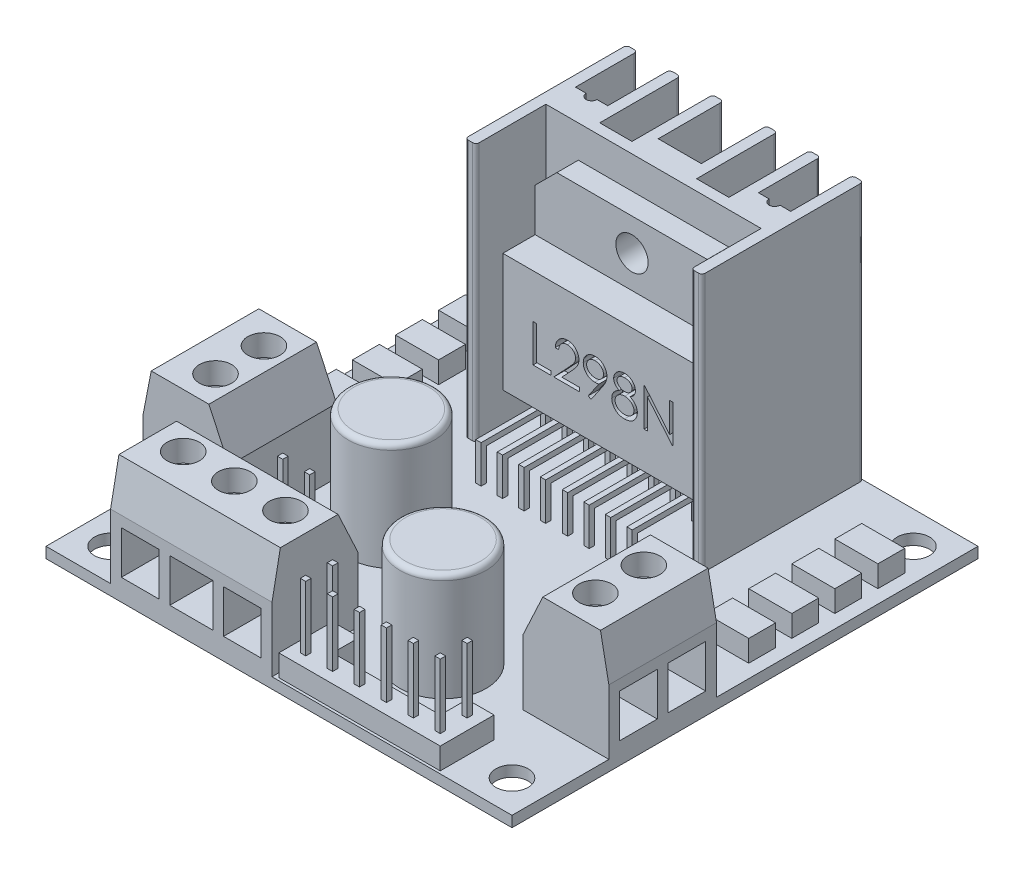
from build123d import *

# Parameters (mm, degrees)
CROQUIS1_W               = 43.3
CROQUIS1_H               = 43.3
CROQUIS1_R               = 1.5
SALIENTE_EXTRUIR1_DEPTH  = 1
CROQUIS2_W               = 1
CROQUIS2_H               = 1
CROQUIS2_H_2             = 6.5
CROQUIS2_W_2             = 3
CROQUIS2_W_3             = 2
CROQUIS2_H_3             = 1.435307759
SALIENTE_EXTRUIR2_DEPTH  = 24
CROQUIS3_W               = 8
CROQUIS3_H               = 10
SALIENTE_EXTRUIR3_DEPTH  = 10
CHAFL_N1_SIZE            = 4
CHAFL_N1_SIZE2           = 1.865230633
CHAFL_N2_SIZE            = 4
CHAFL_N2_SIZE2           = 1.865230633
CHAFL_N3_SIZE            = 4
CHAFL_N3_SIZE2           = 0.777521237
CHAFL_N4_SIZE            = 4
CHAFL_N4_SIZE2           = 0.777521237
CROQUIS4_W               = 15
CROQUIS4_H               = 8
SALIENTE_EXTRUIR4_DEPTH  = 10
CHAFL_N5_SIZE            = 4
CHAFL_N5_SIZE2           = 0.777521237
CHAFL_N6_SIZE            = 4
CHAFL_N6_SIZE2           = 1.865230633
CROQUIS5_W               = 4
CROQUIS5_H               = 2.5
SALIENTE_EXTRUIR5_DEPTH  = 2
CROQUIS6_R               = 4
SALIENTE_EXTRUIR6_DEPTH  = 10
REDONDEO1_R              = 0.5
SALIENTE_EXTRUIR7_DEPTH  = 2
CROQUIS8_W               = 2.5
CROQUIS8_H               = 2.5
SALIENTE_EXTRUIR8_DEPTH  = 2
CROQUIS9_W               = 0.25
CROQUIS9_H               = 0.25
CROQUIS9_H_2             = 0.5
CROQUIS9_W_2             = 0.5
SALIENTE_EXTRUIR9_DEPTH  = 6
CROQUIS10_W              = 0.5
CROQUIS10_H              = 0.5
SALIENTE_EXTRUIR10_DEPTH = 6
CROQUIS11_W              = 9
CROQUIS11_H              = 10
SALIENTE_EXTRUIR11_DEPTH = 5
CORTAR_EXTRUIR1_DEPTH    = 3
CROQUIS13_W              = 0.5
CROQUIS13_H              = 0.5
SALIENTE_EXTRUIR12_DEPTH = 1
CROQUIS14_W              = 0.5
CROQUIS14_H              = 0.5
SALIENTE_EXTRUIR13_DEPTH = 7
CROQUIS15_W              = 0.5
CROQUIS15_H              = 0.5
SALIENTE_EXTRUIR14_DEPTH = 4
CROQUIS16_W              = 0.5
CROQUIS16_H              = 0.5
SALIENTE_EXTRUIR15_DEPTH = 4
CORTAR_EXTRUIR2_DEPTH    = 1
CROQUIS18_R              = 1.5
CORTAR_EXTRUIR3_DEPTH    = 11.5
CROQUIS19_W              = 3.5
CROQUIS19_H              = 4
CORTAR_EXTRUIR4_DEPTH    = 4
CROQUIS20_W              = 3.5
CROQUIS20_H              = 4
CROQUIS20_W_2            = 4
CORTAR_EXTRUIR5_DEPTH    = 4
CROQUIS21_W              = 3.5
CROQUIS21_H              = 4
CORTAR_EXTRUIR6_DEPTH    = 4
CROQUIS22_R              = 1.5
CORTAR_EXTRUIR7_DEPTH    = 2
REDONDEO2_R              = 0.3
ECHELLE1_SCALE           = 1.6


with BuildPart() as part:
    # Croquis1 → Saliente-Extruir1 (new body)
    with BuildSketch(Plane(origin=(0, 0, 0), x_dir=(1, 0, 0), z_dir=(0, 1, 0))):
        with Locations((-21.65, -21.65)):
            Rectangle(CROQUIS1_W, CROQUIS1_H)
        with Locations((-40.3, -3)):
            Circle(CROQUIS1_R, mode=Mode.SUBTRACT)
        with Locations((-3, -3)):
            Circle(CROQUIS1_R, mode=Mode.SUBTRACT)
        with Locations((-40.3, -40.3)):
            Circle(CROQUIS1_R, mode=Mode.SUBTRACT)
        with Locations((-3, -40.3)):
            Circle(CROQUIS1_R, mode=Mode.SUBTRACT)
    extrude(amount=SALIENTE_EXTRUIR1_DEPTH)

    # Croquis2 → Saliente-Extruir2 (add)
    with BuildSketch(Plane(origin=(0, 1, 0), x_dir=(-1, 0, 0), z_dir=(0, 1, 0))):
        Polygon((31.65, 5.75316787), (31.65, 0), (32.65, 0), (32.65, 7.5), (31.65, 7.5), align=None)
        with Locations((32.15, 8)):
            Rectangle(CROQUIS2_W, CROQUIS2_H)
        with Locations((32.15, 11.75)):
            Rectangle(CROQUIS2_W, CROQUIS2_H_2)
        with Locations((30.15, 8)):
            Rectangle(CROQUIS2_W_2, CROQUIS2_H)
        with Locations((28.15, 8)):
            Rectangle(CROQUIS2_W, CROQUIS2_H)
        with BuildLine():
            Line((31.65, 7.5), (28.65, 7.5))
            Line((28.65, 7.5), (28.65, 5.75316787))
            Line((28.65, 5.75316787), (29.645779613, 5.75316787))
            ThreePointArc((29.645779613, 5.75316787), (30.15, 6.257388257), (30.654220387, 5.75316787))
            Line((30.654220387, 5.75316787), (31.65, 5.75316787))
            Line((31.65, 5.75316787), (31.65, 7.5))
        make_face()
        with Locations((22.65, 6.782346121)):
            Rectangle(CROQUIS2_W_3, CROQUIS2_H_3)
        with Locations((20.65, 6.782346121)):
            Rectangle(CROQUIS2_W_3, CROQUIS2_H_3)
        Polygon((23.65, 6.064692241), (23.65, 0), (24.65, 0), (24.65, 7.5), (23.65, 7.5), align=None)
        Polygon((27.65, 7.5), (27.65, 0), (28.65, 0), (28.65, 5.75316787), (28.65, 7.5), align=None)
        with Locations((26.15, 8)):
            Rectangle(CROQUIS2_W_2, CROQUIS2_H)
        with Locations((24.15, 8)):
            Rectangle(CROQUIS2_W, CROQUIS2_H)
        with Locations((22.65, 8)):
            Rectangle(CROQUIS2_W_3, CROQUIS2_H)
        with Locations((20.65, 8)):
            Rectangle(CROQUIS2_W_3, CROQUIS2_H)
        with Locations((19.15, 8)):
            Rectangle(CROQUIS2_W, CROQUIS2_H)
        Polygon((18.65, 7.5), (18.65, 0), (19.65, 0), (19.65, 6.064692241), (19.65, 7.5), align=None)
        with Locations((17.15, 8)):
            Rectangle(CROQUIS2_W_2, CROQUIS2_H)
        with Locations((15.15, 8)):
            Rectangle(CROQUIS2_W, CROQUIS2_H)
        with Locations((13.15, 8)):
            Rectangle(CROQUIS2_W_2, CROQUIS2_H)
        with Locations((11.15, 11.75)):
            Rectangle(CROQUIS2_W, CROQUIS2_H_2)
        with Locations((11.15, 8)):
            Rectangle(CROQUIS2_W, CROQUIS2_H)
        Polygon((10.65, 7.5), (10.65, 0), (11.65, 0), (11.65, 5.75316787), (11.65, 7.5), align=None)
        with BuildLine():
            Line((14.65, 7.5), (11.65, 7.5))
            Line((11.65, 7.5), (11.65, 5.75316787))
            Line((11.65, 5.75316787), (12.645779613, 5.75316787))
            ThreePointArc((12.645779613, 5.75316787), (13.15, 6.257388257), (13.654220387, 5.75316787))
            Line((13.654220387, 5.75316787), (14.65, 5.75316787))
            Line((14.65, 5.75316787), (14.65, 7.5))
        make_face()
        Polygon((14.65, 5.75316787), (14.65, 0), (15.65, 0), (15.65, 7.5), (14.65, 7.5), align=None)
    extrude(amount=SALIENTE_EXTRUIR2_DEPTH)

    # Croquis3 → Saliente-Extruir3 (add)
    with BuildSketch(Plane(origin=(0, 1, 0), x_dir=(-1, 0, 0), z_dir=(0, 1, 0))):
        with Locations((39.3, 29.3)):
            Rectangle(CROQUIS3_W, CROQUIS3_H)
        with Locations((4, 29.3)):
            Rectangle(CROQUIS3_W, CROQUIS3_H)
    extrude(amount=SALIENTE_EXTRUIR3_DEPTH)

    # Chaflán1
    chafl_n1_edges = [part.edges().sort_by_distance(p)[0] for p in [
        (-35.3, 11, 29.3),
    ]]
    chafl_n1_side = [part.faces().sort_by_distance(p)[0] for p in [
        (-35.3, 6, 29.3),
    ]]
    chamfer(chafl_n1_edges, length=CHAFL_N1_SIZE, length2=CHAFL_N1_SIZE2, reference=chafl_n1_side[0])

    # Chaflán2
    chafl_n2_edges = [part.edges().sort_by_distance(p)[0] for p in [
        (-8, 11, 29.3),
    ]]
    chafl_n2_side = [part.faces().sort_by_distance(p)[0] for p in [
        (-8, 6, 29.3),
    ]]
    chamfer(chafl_n2_edges, length=CHAFL_N2_SIZE, length2=CHAFL_N2_SIZE2, reference=chafl_n2_side[0])

    # Chaflán3
    chafl_n3_edges = [part.edges().sort_by_distance(p)[0] for p in [
        (0, 11, 29.3),
    ]]
    chafl_n3_side = [part.faces().sort_by_distance(p)[0] for p in [
        (0, 4.338101884, 26.988450803),
    ]]
    chamfer(chafl_n3_edges, length=CHAFL_N3_SIZE, length2=CHAFL_N3_SIZE2, reference=chafl_n3_side[0])

    # Chaflán4
    chafl_n4_edges = [part.edges().sort_by_distance(p)[0] for p in [
        (-43.3, 11, 29.3),
    ]]
    chafl_n4_side = [part.faces().sort_by_distance(p)[0] for p in [
        (-43.3, 4.338101884, 26.988450803),
    ]]
    chamfer(chafl_n4_edges, length=CHAFL_N4_SIZE, length2=CHAFL_N4_SIZE2, reference=chafl_n4_side[0])

    # Croquis4 → Saliente-Extruir4 (add)
    with BuildSketch(Plane(origin=(0, 1, 0), x_dir=(-1, 0, 0), z_dir=(0, 1, 0))):
        with Locations((29.8, 39.3)):
            Rectangle(CROQUIS4_W, CROQUIS4_H)
    extrude(amount=SALIENTE_EXTRUIR4_DEPTH)

    # Chaflán5
    chafl_n5_edges = [part.edges().sort_by_distance(p)[0] for p in [
        (-29.8, 11, 43.3),
    ]]
    chafl_n5_side = [part.faces().sort_by_distance(p)[0] for p in [
        (-27.97436627, 4.767977237, 43.3),
    ]]
    chamfer(chafl_n5_edges, length=CHAFL_N5_SIZE, length2=CHAFL_N5_SIZE2, reference=chafl_n5_side[0])

    # Chaflán6
    chafl_n6_edges = [part.edges().sort_by_distance(p)[0] for p in [
        (-29.8, 11, 35.3),
    ]]
    chafl_n6_side = [part.faces().sort_by_distance(p)[0] for p in [
        (-29.8, 6, 35.3),
    ]]
    chamfer(chafl_n6_edges, length=CHAFL_N6_SIZE, length2=CHAFL_N6_SIZE2, reference=chafl_n6_side[0])

    # Croquis5 → Saliente-Extruir5 (add)
    with BuildSketch(Plane(origin=(0, 1, 0), x_dir=(-1, 0, 0), z_dir=(0, 1, 0))):
        with Locations((40.060783052, 10.814133786)):
            Rectangle(CROQUIS5_W, CROQUIS5_H)
        with Locations((40.060783052, 6.814133786)):
            Rectangle(CROQUIS5_W, CROQUIS5_H)
        with Locations((40.060783052, 14.814133786)):
            Rectangle(CROQUIS5_W, CROQUIS5_H)
        with Locations((40.060783052, 18.814133786)):
            Rectangle(CROQUIS5_W, CROQUIS5_H)
        with Locations((3.239216948, 6.814133786)):
            Rectangle(CROQUIS5_W, CROQUIS5_H)
        with Locations((3.239216948, 10.814133786)):
            Rectangle(CROQUIS5_W, CROQUIS5_H)
        with Locations((3.239216948, 14.814133786)):
            Rectangle(CROQUIS5_W, CROQUIS5_H)
        with Locations((3.239216948, 18.814133786)):
            Rectangle(CROQUIS5_W, CROQUIS5_H)
    extrude(amount=SALIENTE_EXTRUIR5_DEPTH)

    # Croquis6 → Saliente-Extruir6 (add)
    with BuildSketch(Plane(origin=(0, 1, 0), x_dir=(-1, 0, 0), z_dir=(0, 1, 0))):
        with Locations((28.3, 26.210008209)):
            Circle(CROQUIS6_R)
        with Locations((15.406645961, 34.3)):
            Circle(CROQUIS6_R)
    extrude(amount=SALIENTE_EXTRUIR6_DEPTH)

    # Redondeo1
    redondeo1_edges = [part.edges().sort_by_distance(p)[0] for p in [
        (-24.3, 11, 26.210008209),
        (-11.406645961, 11, 34.3),
    ]]
    fillet(redondeo1_edges, radius=REDONDEO1_R)

    # Croquis7 → Saliente-Extruir7 (add)
    with BuildSketch(Plane(origin=(0, 1, 0), x_dir=(-1, 0, 0), z_dir=(0, 1, 0))):
        Polygon((19.407725127, 40.559550143), (19.407725127, 38.059550143), (21.907725127, 38.059550143), (21.907725127, 40.559550143), (21.907725127, 43.059550143), (6.907725127, 43.059550143), (6.907725127, 38.059550143), (9.407725127, 38.059550143), (9.407725127, 40.559550143), align=None)
    extrude(amount=SALIENTE_EXTRUIR7_DEPTH)

    # Croquis8 → Saliente-Extruir8 (add)
    with BuildSketch(Plane(origin=(0, 1, 0), x_dir=(-1, 0, 0), z_dir=(0, 1, 0))):
        with Locations((29.05, 33.05)):
            Rectangle(CROQUIS8_W, CROQUIS8_H)
        with Locations((31.55, 33.05)):
            Rectangle(CROQUIS8_W, CROQUIS8_H)
    extrude(amount=SALIENTE_EXTRUIR8_DEPTH)

    # Croquis9 → Saliente-Extruir9 (add)
    with BuildSketch(Plane(origin=(0, 3, 0), x_dir=(-1, 0, 0), z_dir=(0, 1, 0))):
        with Locations((20.532725127, 41.934550143)):
            Rectangle(CROQUIS9_W, CROQUIS9_H)
        with Locations((20.532725127, 41.684550143)):
            Rectangle(CROQUIS9_W, CROQUIS9_H)
        with Locations((20.782725127, 41.934550143)):
            Rectangle(CROQUIS9_W, CROQUIS9_H)
        with Locations((20.782725127, 41.684550143)):
            Rectangle(CROQUIS9_W, CROQUIS9_H)
        with Locations((20.532725127, 39.309550143)):
            Rectangle(CROQUIS9_W, CROQUIS9_H_2)
        with Locations((20.782725127, 39.309550143)):
            Rectangle(CROQUIS9_W, CROQUIS9_H_2)
        with Locations((18.157725127, 41.684550143)):
            Rectangle(CROQUIS9_W_2, CROQUIS9_H)
        with Locations((18.157725127, 41.934550143)):
            Rectangle(CROQUIS9_W_2, CROQUIS9_H)
        with Locations((15.657725127, 41.684550143)):
            Rectangle(CROQUIS9_W_2, CROQUIS9_H)
        with Locations((15.657725127, 41.934550143)):
            Rectangle(CROQUIS9_W_2, CROQUIS9_H)
        with Locations((13.157725127, 41.934550143)):
            Rectangle(CROQUIS9_W_2, CROQUIS9_H)
        with Locations((13.157725127, 41.684550143)):
            Rectangle(CROQUIS9_W_2, CROQUIS9_H)
        with Locations((10.657725127, 41.934550143)):
            Rectangle(CROQUIS9_W_2, CROQUIS9_H)
        with Locations((10.657725127, 41.684550143)):
            Rectangle(CROQUIS9_W_2, CROQUIS9_H)
        with Locations((8.032725127, 41.934550143)):
            Rectangle(CROQUIS9_W, CROQUIS9_H)
        with Locations((8.032725127, 41.684550143)):
            Rectangle(CROQUIS9_W, CROQUIS9_H)
        with Locations((8.282725127, 41.684550143)):
            Rectangle(CROQUIS9_W, CROQUIS9_H)
        with Locations((8.282725127, 41.934550143)):
            Rectangle(CROQUIS9_W, CROQUIS9_H)
        with Locations((8.032725127, 39.309550143)):
            Rectangle(CROQUIS9_W, CROQUIS9_H_2)
        with Locations((8.282725127, 39.309550143)):
            Rectangle(CROQUIS9_W, CROQUIS9_H_2)
    extrude(amount=SALIENTE_EXTRUIR9_DEPTH)

    # Croquis10 → Saliente-Extruir10 (add)
    with BuildSketch(Plane(origin=(0, 3, 0), x_dir=(1, 0, 0), z_dir=(0, 1, 0))):
        with Locations((-29.05, -33.05)):
            Rectangle(CROQUIS10_W, CROQUIS10_H)
        with Locations((-31.55, -33.05)):
            Rectangle(CROQUIS10_W, CROQUIS10_H)
    extrude(amount=SALIENTE_EXTRUIR10_DEPTH)

    # Croquis11 → Saliente-Extruir11 (add)
    with BuildSketch(Plane.XY.offset(8.5)):
        Polygon((-21.65, 15), (-21.65, 22), (-28.637466442, 22), (-30.65, 19.987466442), (-30.65, 15), align=None)
        Polygon((-14.662533558, 22), (-21.65, 22), (-21.65, 15), (-12.65, 15), (-12.65, 19.987466442), align=None)
        with Locations((-26.15, 10)):
            Rectangle(CROQUIS11_W, CROQUIS11_H)
        with Locations((-17.15, 10)):
            Rectangle(CROQUIS11_W, CROQUIS11_H)
    extrude(amount=SALIENTE_EXTRUIR11_DEPTH)

    # Croquis12 → Cortar-Extruir1 (cut)
    with BuildSketch(Plane.XY.offset(13.5)):
        Polygon((-14.662533558, 22), (-28.637466442, 22), (-30.65, 19.987466442), (-30.65, 16), (-12.65, 16), (-12.65, 19.987466442), align=None)
    extrude(amount=-CORTAR_EXTRUIR1_DEPTH, mode=Mode.SUBTRACT)

    # Croquis13 → Saliente-Extruir12 (add)
    with BuildSketch(Plane.XZ.offset(-5)):
        with Locations((-28.173070454, 11)):
            Rectangle(CROQUIS13_W, CROQUIS13_H)
        with Locations((-29.173070454, 11)):
            Rectangle(CROQUIS13_W, CROQUIS13_H)
        with Locations((-27.173070454, 11)):
            Rectangle(CROQUIS13_W, CROQUIS13_H)
        with Locations((-26.173070454, 11)):
            Rectangle(CROQUIS13_W, CROQUIS13_H)
        with Locations((-25.173070454, 11)):
            Rectangle(CROQUIS13_W, CROQUIS13_H)
        with Locations((-24.173070454, 11)):
            Rectangle(CROQUIS13_W, CROQUIS13_H)
        with Locations((-23.173070454, 11)):
            Rectangle(CROQUIS13_W, CROQUIS13_H)
        with Locations((-22.173070454, 11)):
            Rectangle(CROQUIS13_W, CROQUIS13_H)
        with Locations((-21.126929546, 11)):
            Rectangle(CROQUIS13_W, CROQUIS13_H)
        with Locations((-20.126929546, 11)):
            Rectangle(CROQUIS13_W, CROQUIS13_H)
        with Locations((-19.126929546, 11)):
            Rectangle(CROQUIS13_W, CROQUIS13_H)
        with Locations((-18.126929546, 11)):
            Rectangle(CROQUIS13_W, CROQUIS13_H)
        with Locations((-17.126929546, 11)):
            Rectangle(CROQUIS13_W, CROQUIS13_H)
        with Locations((-16.126929546, 11)):
            Rectangle(CROQUIS13_W, CROQUIS13_H)
        with Locations((-15.126929546, 11)):
            Rectangle(CROQUIS13_W, CROQUIS13_H)
        with Locations((-14.126929546, 11)):
            Rectangle(CROQUIS13_W, CROQUIS13_H)
    extrude(amount=SALIENTE_EXTRUIR12_DEPTH)

    # Croquis14 → Saliente-Extruir13 (add)
    with BuildSketch(Plane.XY.offset(11.25)):
        with Locations((-14.126929546, 4.25)):
            Rectangle(CROQUIS14_W, CROQUIS14_H)
        with Locations((-16.126929546, 4.25)):
            Rectangle(CROQUIS14_W, CROQUIS14_H)
        with Locations((-18.126929546, 4.25)):
            Rectangle(CROQUIS14_W, CROQUIS14_H)
        with Locations((-20.126929546, 4.25)):
            Rectangle(CROQUIS14_W, CROQUIS14_H)
        with Locations((-22.173070454, 4.25)):
            Rectangle(CROQUIS14_W, CROQUIS14_H)
        with Locations((-24.173070454, 4.25)):
            Rectangle(CROQUIS14_W, CROQUIS14_H)
        with Locations((-26.173070454, 4.25)):
            Rectangle(CROQUIS14_W, CROQUIS14_H)
        with Locations((-28.173070454, 4.25)):
            Rectangle(CROQUIS14_W, CROQUIS14_H)
    extrude(amount=SALIENTE_EXTRUIR13_DEPTH)

    # Croquis15 → Saliente-Extruir14 (add)
    with BuildSketch(Plane.XZ):
        with Locations((-28.173070454, 18)):
            Rectangle(CROQUIS15_W, CROQUIS15_H)
        with Locations((-26.173070454, 18)):
            Rectangle(CROQUIS15_W, CROQUIS15_H)
        with Locations((-24.173070454, 18)):
            Rectangle(CROQUIS15_W, CROQUIS15_H)
        with Locations((-22.173070454, 18)):
            Rectangle(CROQUIS15_W, CROQUIS15_H)
        with Locations((-20.126929546, 18)):
            Rectangle(CROQUIS15_W, CROQUIS15_H)
        with Locations((-18.126929546, 18)):
            Rectangle(CROQUIS15_W, CROQUIS15_H)
        with Locations((-16.126929546, 18)):
            Rectangle(CROQUIS15_W, CROQUIS15_H)
        with Locations((-14.126929546, 18)):
            Rectangle(CROQUIS15_W, CROQUIS15_H)
    extrude(amount=-SALIENTE_EXTRUIR14_DEPTH)

    # Croquis16 → Saliente-Extruir15 (add)
    with BuildSketch(Plane.XZ):
        with Locations((-29.173070454, 11)):
            Rectangle(CROQUIS16_W, CROQUIS16_H)
        with Locations((-27.173070454, 11)):
            Rectangle(CROQUIS16_W, CROQUIS16_H)
        with Locations((-25.173070454, 11)):
            Rectangle(CROQUIS16_W, CROQUIS16_H)
        with Locations((-23.173070454, 11)):
            Rectangle(CROQUIS16_W, CROQUIS16_H)
        with Locations((-21.126929546, 11)):
            Rectangle(CROQUIS16_W, CROQUIS16_H)
        with Locations((-19.126929546, 11)):
            Rectangle(CROQUIS16_W, CROQUIS16_H)
        with Locations((-17.126929546, 11)):
            Rectangle(CROQUIS16_W, CROQUIS16_H)
        with Locations((-15.126929546, 11)):
            Rectangle(CROQUIS16_W, CROQUIS16_H)
    extrude(amount=-SALIENTE_EXTRUIR15_DEPTH)

    # Croquis17 → Cortar-Extruir2 (cut)
    with BuildSketch(Plane.XY.offset(13.5)):
        Polygon((-27.846931762, 11.915865738), (-27.532829198, 11.915865738), (-27.532829198, 8.774840097), (-26.186675351, 8.774840097), (-26.186675351, 8.415865738), (-27.846931762, 8.415865738), align=None)
        with BuildLine():
            Line((-25.468726633, 10.838942661), (-25.782829198, 10.838942661))
            add(Edge.make_bspline(
                [(-25.782829198, 10.838942661), (-25.780782045, 10.880613549), (-25.77676149, 10.962454063), (-25.757933201, 11.08177797), (-25.730992324, 11.195832768), (-25.69290087, 11.303702682), (-25.645594592, 11.40634149), (-25.588864565, 11.503341505), (-25.521670714, 11.594332694), (-25.44546398, 11.678471537), (-25.362695341, 11.755659108), (-25.273389402, 11.822314351), (-25.179544374, 11.878632022), (-25.081444976, 11.925713264), (-24.977984412, 11.96105311), (-24.870101554, 11.98727475), (-24.757322418, 12.003051095), (-24.680482396, 12.004746881), (-24.641402915, 12.005609328)],
                knots=[0, 0, 0, 0, 0.000125083, 0.00024566, 0.000361805, 0.000476223, 0.000588214, 0.000700404, 0.000812728, 0.00092691, 0.001040529, 0.001151727, 0.001260545, 0.001368429, 0.001477521, 0.001587884, 0.001701119, 0.00181831, 0.00181831, 0.00181831, 0.00181831], degree=3))
            add(Edge.make_bspline(
                [(-24.641402915, 12.005609328), (-24.603024841, 12.004710871), (-24.527613297, 12.002945436), (-24.417551282, 11.987784407), (-24.312773988, 11.964038815), (-24.213486221, 11.930723399), (-24.120480157, 11.885938972), (-24.033057112, 11.832141433), (-23.950176301, 11.769921602), (-23.875569518, 11.696667788), (-23.807061439, 11.618465404), (-23.747959183, 11.5349775), (-23.69734602, 11.448748214), (-23.65515834, 11.359120013), (-23.624102201, 11.265248985), (-23.600523993, 11.168501782), (-23.587196579, 11.067876971), (-23.585151156, 10.999770415), (-23.584111249, 10.965144584)],
                knots=[0, 0, 0, 0, 0.000115089, 0.000226145, 0.000332614, 0.000437044, 0.000539592, 0.000641561, 0.000744629, 0.00084975, 0.000954621, 0.001056175, 0.001156101, 0.001254284, 0.001352726, 0.001452208, 0.001552655, 0.001656537, 0.001656537, 0.001656537, 0.001656537], degree=3))
            add(Edge.make_bspline(
                [(-23.584111249, 10.965144584), (-23.585804512, 10.916396749), (-23.589161323, 10.819756536), (-23.6178757, 10.677741673), (-23.662722211, 10.540148254), (-23.716719568, 10.429410952), (-23.771192012, 10.340177458), (-23.820279519, 10.266708753), (-23.87774433, 10.187603285), (-23.944422828, 10.103125947), (-24.0189357, 10.012615042), (-24.101957864, 9.916125247), (-24.194081346, 9.814653477), (-24.258739846, 9.745347876), (-24.292244262, 9.709435449)],
                knots=[0, 0, 0, 0, 0.000146118, 0.000289672, 0.0004329, 0.00057934, 0.000657978, 0.000746456, 0.000844345, 0.000951219, 0.001069268, 0.00119604, 0.001333047, 0.001480391, 0.001480391, 0.001480391, 0.001480391], degree=3))
            Line((-24.292244262, 9.709435449), (-25.167945383, 8.774840097))
            Line((-25.167945383, 8.774840097), (-23.539239454, 8.774840097))
            Line((-23.539239454, 8.774840097), (-23.539239454, 8.415865738))
            Line((-23.539239454, 8.415865738), (-25.917444582, 8.415865738))
            Line((-25.917444582, 8.415865738), (-24.560072787, 9.864383366))
            add(Edge.make_bspline(
                [(-24.560072787, 9.864383366), (-24.5270249, 9.898881673), (-24.463546673, 9.965145859), (-24.373764097, 10.061888819), (-24.293125108, 10.15163836), (-24.221107715, 10.234224909), (-24.15927421, 10.310856476), (-24.104401978, 10.37905118), (-24.060436387, 10.44180563), (-24.012720991, 10.514546244), (-23.96650701, 10.603358561), (-23.926794654, 10.711892251), (-23.902579806, 10.823619503), (-23.89967497, 10.89912154), (-23.898213813, 10.937099712)],
                knots=[0, 0, 0, 0, 0.000143319, 0.000275286, 0.00039593, 0.000505287, 0.000603949, 0.000691331, 0.000767782, 0.00083371, 0.000952247, 0.001067137, 0.001179618, 0.001293462, 0.001293462, 0.001293462, 0.001293462], degree=3))
            add(Edge.make_bspline(
                [(-23.898213813, 10.937099712), (-23.898849555, 10.960981111), (-23.900102481, 11.008046761), (-23.911160179, 11.07705252), (-23.927870685, 11.143617334), (-23.951815943, 11.207945953), (-23.983422683, 11.269391605), (-24.021896063, 11.328029085), (-24.066286126, 11.38471805), (-24.117637396, 11.437871349), (-24.174048915, 11.486552554), (-24.233643165, 11.529676639), (-24.296693269, 11.56571575), (-24.362933391, 11.595259247), (-24.432178861, 11.618434629), (-24.504563606, 11.634493208), (-24.579887622, 11.644575692), (-24.631321118, 11.645939864), (-24.657528717, 11.646634969)],
                knots=[0, 0, 0, 0, 7.16e-05, 0.00014111, 0.00020913, 0.00027724, 0.000346538, 0.000415963, 0.000487357, 0.000562233, 0.000637292, 0.000710646, 0.000782564, 0.000854749, 0.000927915, 0.001001225, 0.001076884, 0.001155488, 0.001155488, 0.001155488, 0.001155488], degree=3))
            add(Edge.make_bspline(
                [(-24.657528717, 11.646634969), (-24.68489955, 11.645919936), (-24.738651346, 11.644515731), (-24.817570379, 11.634693067), (-24.892856156, 11.617747227), (-24.964698059, 11.594570552), (-25.033217645, 11.565112004), (-25.098081689, 11.528420259), (-25.159144578, 11.484636766), (-25.216521102, 11.434996209), (-25.269385081, 11.379728608), (-25.315831957, 11.318118645), (-25.356415971, 11.25129123), (-25.391825204, 11.179426679), (-25.420580894, 11.101872899), (-25.442554045, 11.018905194), (-25.459940891, 10.930883813), (-25.465749412, 10.870098728), (-25.468726633, 10.838942661)],
                knots=[0, 0, 0, 0, 8.2106e-05, 0.000161243, 0.000238127, 0.000313291, 0.000387401, 0.000461495, 0.000536397, 0.000612445, 0.000688819, 0.000765383, 0.000843422, 0.000923066, 0.001005373, 0.001091093, 0.001180334, 0.001274175, 0.001274175, 0.001274175, 0.001274175], degree=3))
        make_face()
        with BuildLine():
            Line((-22.462316377, 8.326122148), (-22.71331798, 8.500701475))
            Line((-22.71331798, 8.500701475), (-21.740160928, 9.923277597))
            add(Edge.make_bspline(
                [(-21.740160928, 9.923277597), (-21.802251664, 9.915684534), (-21.924511784, 9.900733369), (-22.047648886, 9.897986714), (-22.108249871, 9.896634969)],
                knots=[0, 0, 0, 0, 0.000187529, 0.000369255, 0.000369255, 0.000369255, 0.000369255], degree=3))
            add(Edge.make_bspline(
                [(-22.108249871, 9.896634969), (-22.144991918, 9.897576045), (-22.217113345, 9.899423296), (-22.323144998, 9.914065104), (-22.425030558, 9.936615232), (-22.522499914, 9.970263987), (-22.615919419, 10.012082196), (-22.705085133, 10.06393921), (-22.789877023, 10.124945501), (-22.869384433, 10.194778493), (-22.941696172, 10.271456545), (-23.00611947, 10.352612188), (-23.059660602, 10.439188159), (-23.104137187, 10.529418378), (-23.137867641, 10.624599729), (-23.162430178, 10.723649129), (-23.177552532, 10.827260771), (-23.179351628, 10.897785902), (-23.180265095, 10.933594103)],
                knots=[0, 0, 0, 0, 0.000110185, 0.000216284, 0.000320547, 0.000422759, 0.000525058, 0.000627155, 0.000731643, 0.000837964, 0.0009441, 0.00104747, 0.001148247, 0.001248901, 0.001348697, 0.001450555, 0.001554666, 0.00166205, 0.00166205, 0.00166205, 0.00166205], degree=3))
            add(Edge.make_bspline(
                [(-23.180265095, 10.933594103), (-23.17853066, 10.982562756), (-23.175126317, 11.078678288), (-23.147727799, 11.219112057), (-23.10266746, 11.3518986), (-23.039839083, 11.476688794), (-22.960704362, 11.591687533), (-22.865595772, 11.695296142), (-22.755091807, 11.786040996), (-22.631709788, 11.864045074), (-22.498356768, 11.926780071), (-22.358688109, 11.973019371), (-22.213773989, 12.000218119), (-22.115606319, 12.00380398), (-22.066182563, 12.005609328)],
                knots=[0, 0, 0, 0, 0.000146818, 0.000288173, 0.000427413, 0.000566316, 0.000705952, 0.000844895, 0.000986821, 0.001133677, 0.001281714, 0.001427825, 0.001574003, 0.00172222, 0.00172222, 0.00172222, 0.00172222], degree=3))
            add(Edge.make_bspline(
                [(-22.066182563, 12.005609328), (-22.017694143, 12.003779165), (-21.921885596, 12.000162935), (-21.78099659, 11.973678966), (-21.646055573, 11.929042293), (-21.517810586, 11.867357729), (-21.399071174, 11.790036822), (-21.292295363, 11.697902298), (-21.199919824, 11.590896771), (-21.122095943, 11.471608281), (-21.059625903, 11.343441299), (-21.01455362, 11.209657377), (-20.986807981, 11.071218656), (-20.983311654, 10.977424181), (-20.981547146, 10.930088494)],
                knots=[0, 0, 0, 0, 0.000145418, 0.000287333, 0.000428343, 0.000570713, 0.000713061, 0.00085223, 0.000992387, 0.001135706, 0.001278381, 0.001418948, 0.001558239, 0.001700158, 0.001700158, 0.001700158, 0.001700158], degree=3))
            add(Edge.make_bspline(
                [(-20.981547146, 10.930088494), (-20.982725555, 10.893344727), (-20.985115663, 10.818819186), (-21.00185197, 10.705588844), (-21.030272155, 10.590137614), (-21.062523854, 10.492416018), (-21.093656022, 10.411707569), (-21.122957153, 10.347955989), (-21.155469307, 10.280854725), (-21.193388072, 10.211107387), (-21.234150369, 10.137824852), (-21.280209646, 10.061742137), (-21.330515217, 9.982757144), (-21.366344937, 9.929510056), (-21.384692178, 9.902243943)],
                knots=[0, 0, 0, 0, 0.000110219, 0.000223552, 0.000342587, 0.000466527, 0.000532018, 0.000601997, 0.000676938, 0.00075567, 0.000840114, 0.000928491, 0.001022434, 0.001121023, 0.001121023, 0.001121023, 0.001121023], degree=3))
            Line((-21.384692178, 9.902243943), (-22.462316377, 8.326122148))
        make_face()
        with BuildLine():
            add(Edge.make_bspline(
                [(-22.050056762, 10.255609328), (-22.022222748, 10.256369711), (-21.968039384, 10.25784992), (-21.888662085, 10.266859162), (-21.813737882, 10.282833148), (-21.743066633, 10.30575286), (-21.675939731, 10.333409529), (-21.613423403, 10.368621515), (-21.555465327, 10.41063815), (-21.5016774, 10.457848166), (-21.453913401, 10.510298749), (-21.41137037, 10.565195856), (-21.375209802, 10.622780466), (-21.346646525, 10.683773728), (-21.32316195, 10.746690937), (-21.306943938, 10.812545292), (-21.297959605, 10.880993693), (-21.29642803, 10.927492351), (-21.29564971, 10.951122148)],
                knots=[0, 0, 0, 0, 8.3507e-05, 0.00016256, 0.000239294, 0.000312908, 0.000385178, 0.000456751, 0.000527578, 0.000599603, 0.000671055, 0.000740051, 0.000807755, 0.000874553, 0.000941763, 0.001008931, 0.001077548, 0.001148448, 0.001148448, 0.001148448, 0.001148448], degree=3))
            add(Edge.make_bspline(
                [(-21.29564971, 10.951122148), (-21.29631938, 10.974761813), (-21.297639045, 11.021346673), (-21.308226344, 11.089896413), (-21.326851568, 11.155589674), (-21.351842052, 11.218786104), (-21.38476229, 11.278966476), (-21.424265776, 11.336886348), (-21.471198226, 11.392178475), (-21.525200792, 11.443542459), (-21.583435345, 11.490890358), (-21.645495845, 11.532676434), (-21.710870761, 11.567697631), (-21.779161251, 11.5965966), (-21.8505096, 11.619148376), (-21.924873588, 11.635365741), (-22.002628994, 11.644337495), (-22.05541028, 11.64585939), (-22.082308364, 11.646634969)],
                knots=[0, 0, 0, 0, 7.09e-05, 0.000139717, 0.000207422, 0.000275384, 0.000343146, 0.000412766, 0.000485392, 0.000560268, 0.000636041, 0.000710323, 0.000784354, 0.000858188, 0.000932471, 0.001008519, 0.001086179, 0.001166885, 0.001166885, 0.001166885, 0.001166885], degree=3))
            add(Edge.make_bspline(
                [(-22.082308364, 11.646634969), (-22.108972518, 11.645858137), (-22.161287367, 11.644334), (-22.238351526, 11.635382794), (-22.312212694, 11.61903931), (-22.383354314, 11.596607046), (-22.451642775, 11.567695475), (-22.517014608, 11.532674599), (-22.579089624, 11.490899977), (-22.637268345, 11.443505204), (-22.691366267, 11.392417558), (-22.737491796, 11.336644129), (-22.777085688, 11.278996605), (-22.809960691, 11.218778097), (-22.834963208, 11.155591811), (-22.85358521, 11.089895834), (-22.864173375, 11.021346824), (-22.865492922, 10.974761864), (-22.866162531, 10.951122148)],
                knots=[0, 0, 0, 0, 8.0005e-05, 0.000156969, 0.000232332, 0.000306614, 0.000380449, 0.000454479, 0.000528762, 0.000604535, 0.000679411, 0.000751586, 0.000821205, 0.000888968, 0.00095693, 0.001024634, 0.001093451, 0.001164351, 0.001164351, 0.001164351, 0.001164351], degree=3))
            add(Edge.make_bspline(
                [(-22.866162531, 10.951122148), (-22.865556605, 10.927473949), (-22.864361608, 10.880835373), (-22.852833818, 10.81230898), (-22.833555538, 10.746620786), (-22.807736147, 10.683132079), (-22.773734557, 10.622460221), (-22.732010709, 10.564892859), (-22.683105163, 10.509777409), (-22.627671676, 10.457970197), (-22.567003515, 10.410418022), (-22.502206769, 10.36888764), (-22.434396932, 10.333815195), (-22.363335301, 10.305673811), (-22.289548501, 10.283062148), (-22.21237337, 10.266888603), (-22.132065132, 10.257936336), (-22.07765515, 10.256392439), (-22.050056762, 10.255609328)],
                knots=[0, 0, 0, 0, 7.09e-05, 0.000139828, 0.000207725, 0.00027595, 0.000345002, 0.000415829, 0.000488844, 0.000565728, 0.000643147, 0.000719775, 0.000796287, 0.0008718, 0.000948761, 0.001027552, 0.001107998, 0.001190805, 0.001190805, 0.001190805, 0.001190805], degree=3))
        make_face(mode=Mode.SUBTRACT)
        with BuildLine():
            add(Edge.make_bspline(
                [(-18.831206601, 10.365685449), (-18.802558054, 10.350747493), (-18.74668382, 10.321613491), (-18.667106611, 10.274702663), (-18.59438161, 10.225261698), (-18.526491048, 10.175625839), (-18.464627698, 10.123894187), (-18.409483285, 10.069861031), (-18.359695665, 10.014875086), (-18.316268881, 9.958005246), (-18.278072044, 9.899402596), (-18.245059909, 9.838913323), (-18.216842706, 9.77666999), (-18.194479767, 9.71199316), (-18.176057976, 9.645832898), (-18.163382371, 9.577334916), (-18.156565453, 9.506950575), (-18.155276639, 9.459382274), (-18.154624069, 9.435296828)],
                knots=[0, 0, 0, 0, 9.692e-05, 0.000189026, 0.000276921, 0.000360637, 0.000441251, 0.000518597, 0.000592078, 0.000663595, 0.000733021, 0.000801734, 0.000870147, 0.000937778, 0.001006834, 0.001076004, 0.001146466, 0.001218736, 0.001218736, 0.001218736, 0.001218736], degree=3))
            add(Edge.make_bspline(
                [(-18.154624069, 9.435296828), (-18.15539549, 9.401599095), (-18.156922421, 9.334898638), (-18.170222405, 9.236452527), (-18.190135383, 9.140840745), (-18.219214895, 9.048084254), (-18.256928286, 8.958694881), (-18.303405122, 8.872596107), (-18.356016327, 8.788376798), (-18.398268567, 8.736557396), (-18.419648108, 8.710336892)],
                knots=[0, 0, 0, 0, 0.000101049, 0.000200014, 0.00029751, 0.000393751, 0.000491154, 0.000588073, 0.000687071, 0.000788472, 0.000788472, 0.000788472, 0.000788472], degree=3))
            add(Edge.make_bspline(
                [(-18.419648108, 8.710336892), (-18.447484582, 8.679743118), (-18.502813548, 8.618933625), (-18.597596475, 8.539982815), (-18.701618359, 8.473633421), (-18.814476692, 8.419561526), (-18.935869793, 8.377475667), (-19.065771798, 8.347233149), (-19.204435951, 8.32991072), (-19.299741422, 8.327406731), (-19.348634486, 8.326122148)],
                knots=[0, 0, 0, 0, 0.000123978, 0.000246423, 0.000368759, 0.000493253, 0.000620972, 0.000753455, 0.000892683, 0.001039354, 0.001039354, 0.001039354, 0.001039354], degree=3))
            add(Edge.make_bspline(
                [(-19.348634486, 8.326122148), (-19.395647875, 8.327274626), (-19.487131154, 8.329517231), (-19.620289031, 8.344711663), (-19.744412101, 8.371339529), (-19.860222069, 8.407784139), (-19.967020763, 8.455194367), (-20.064503864, 8.514202776), (-20.154077836, 8.582434218), (-20.23302431, 8.661848296), (-20.303112753, 8.746906168), (-20.364680807, 8.834657778), (-20.415854885, 8.925111136), (-20.45918198, 9.016917503), (-20.492350003, 9.111363657), (-20.515322213, 9.20796367), (-20.529911527, 9.306548813), (-20.531852662, 9.373080466), (-20.532829198, 9.406550834)],
                knots=[0, 0, 0, 0, 0.000141037, 0.000274444, 0.00040137, 0.000521327, 0.000638076, 0.000750983, 0.00086247, 0.000975011, 0.001086056, 0.001192834, 0.001296147, 0.001397463, 0.001497025, 0.001595826, 0.001694979, 0.00179536, 0.00179536, 0.00179536, 0.00179536], degree=3))
            add(Edge.make_bspline(
                [(-20.532829198, 9.406550834), (-20.532251316, 9.431110026), (-20.53110922, 9.479647658), (-20.523204371, 9.551356986), (-20.51049591, 9.621153121), (-20.493236453, 9.689293865), (-20.469845427, 9.755283137), (-20.441603294, 9.819433611), (-20.408671341, 9.88181771), (-20.370590176, 9.942776591), (-20.326288152, 10.001456103), (-20.276124502, 10.058852098), (-20.219096634, 10.114073965), (-20.155838975, 10.16779639), (-20.087074435, 10.220972364), (-20.011016905, 10.270728092), (-19.929682637, 10.320586057), (-19.871877231, 10.350394382), (-19.84222423, 10.365685449)],
                knots=[0, 0, 0, 0, 7.3671e-05, 0.0001456, 0.000216149, 0.000286381, 0.000356229, 0.000425923, 0.00049649, 0.000567687, 0.000641305, 0.000716824, 0.000796154, 0.000879197, 0.00096572, 0.001056725, 0.001151716, 0.001251771, 0.001251771, 0.001251771, 0.001251771], degree=3))
            add(Edge.make_bspline(
                [(-19.84222423, 10.365685449), (-19.882815604, 10.387820218), (-19.961411867, 10.430679326), (-20.065481308, 10.509426132), (-20.154871932, 10.594713947), (-20.227126649, 10.688343741), (-20.283998877, 10.787390616), (-20.323017482, 10.891234868), (-20.349413966, 10.997950982), (-20.352028793, 11.070857178), (-20.353342018, 11.107472308)],
                knots=[0, 0, 0, 0, 0.000138535, 0.000268243, 0.000390218, 0.00050816, 0.000621822, 0.000731457, 0.000840134, 0.00094978, 0.00094978, 0.00094978, 0.00094978], degree=3))
            add(Edge.make_bspline(
                [(-20.353342018, 11.107472308), (-20.351706594, 11.144769867), (-20.348419106, 11.219744464), (-20.321835786, 11.331350587), (-20.278515719, 11.440967152), (-20.219594722, 11.548062865), (-20.146207506, 11.64901308), (-20.05816096, 11.739554026), (-19.957557663, 11.818865508), (-19.844899796, 11.885441681), (-19.723663561, 11.93962534), (-19.595747837, 11.977003763), (-19.463381344, 12.001439879), (-19.373283624, 12.004206534), (-19.327600832, 12.005609328)],
                knots=[0, 0, 0, 0, 0.000111795, 0.000224728, 0.000342168, 0.000464543, 0.000590474, 0.000715423, 0.000842224, 0.000973648, 0.001107055, 0.001239485, 0.001372621, 0.001509557, 0.001509557, 0.001509557, 0.001509557], degree=3))
            add(Edge.make_bspline(
                [(-19.327600832, 12.005609328), (-19.283097017, 12.004162985), (-19.195340564, 12.001310961), (-19.066345936, 11.977524083), (-18.942921059, 11.937794563), (-18.82549156, 11.88389734), (-18.716159693, 11.817510399), (-18.619557383, 11.737109525), (-18.534224801, 11.646967974), (-18.463640407, 11.546048371), (-18.405477518, 11.439364177), (-18.364976617, 11.327741656), (-18.339024643, 11.213592597), (-18.335751278, 11.136354593), (-18.334111249, 11.097656603)],
                knots=[0, 0, 0, 0, 0.000133436, 0.000263121, 0.000391946, 0.000521517, 0.000649943, 0.000774455, 0.000897469, 0.001021193, 0.0011429, 0.001260905, 0.001376422, 0.001492413, 0.001492413, 0.001492413, 0.001492413], degree=3))
            add(Edge.make_bspline(
                [(-18.334111249, 11.097656603), (-18.335545809, 11.059679939), (-18.338363205, 10.98509593), (-18.362063145, 10.87636941), (-18.401976458, 10.774547371), (-18.456470621, 10.678474419), (-18.527496109, 10.589892921), (-18.614104842, 10.507676451), (-18.71560632, 10.431149623), (-18.791867206, 10.387963258), (-18.831206601, 10.365685449)],
                knots=[0, 0, 0, 0, 0.000113843, 0.000223582, 0.000331909, 0.000440874, 0.000553657, 0.00067118, 0.000798364, 0.000933876, 0.000933876, 0.000933876, 0.000933876], degree=3))
        make_face()
        with BuildLine():
            add(Edge.make_bspline(
                [(-19.345128877, 11.646634969), (-19.369679683, 11.645983528), (-19.417711794, 11.644709026), (-19.488140465, 11.638050389), (-19.555112832, 11.625097172), (-19.619328633, 11.60785846), (-19.679907445, 11.584570472), (-19.737672, 11.557175463), (-19.79163919, 11.523869397), (-19.842460493, 11.486508199), (-19.888211267, 11.445415293), (-19.928815819, 11.402601575), (-19.962543933, 11.357226182), (-19.991185043, 11.310417823), (-20.01196656, 11.260787247), (-20.027530864, 11.20985607), (-20.038052255, 11.156980686), (-20.038840645, 11.120844176), (-20.039239454, 11.102564456)],
                knots=[0, 0, 0, 0, 7.3671e-05, 0.000144133, 0.000211925, 0.000278091, 0.000343329, 0.00040636, 0.000469609, 0.000533272, 0.00059534, 0.000653874, 0.000709964, 0.000764674, 0.00081807, 0.000870854, 0.000924347, 0.000979106, 0.000979106, 0.000979106, 0.000979106], degree=3))
            add(Edge.make_bspline(
                [(-20.039239454, 11.102564456), (-20.038552087, 11.084283946), (-20.037193751, 11.048159033), (-20.026688623, 10.994813167), (-20.011031768, 10.942391531), (-19.986381107, 10.89214062), (-19.956814749, 10.84231726), (-19.920323273, 10.794166674), (-19.876834245, 10.74752129), (-19.827806804, 10.702777848), (-19.774395267, 10.660879085), (-19.717811223, 10.624505904), (-19.658764832, 10.594071793), (-19.597862763, 10.568742388), (-19.534484315, 10.549052451), (-19.469017842, 10.535083805), (-19.40145234, 10.526401808), (-19.355671759, 10.525364787), (-19.332508685, 10.524840097)],
                knots=[0, 0, 0, 0, 5.48e-05, 0.000108292, 0.000162623, 0.00021845, 0.000275685, 0.000336262, 0.000399273, 0.000466763, 0.000535204, 0.00060269, 0.000668229, 0.000734243, 0.000800327, 0.000867022, 0.000934854, 0.001004321, 0.001004321, 0.001004321, 0.001004321], degree=3))
            add(Edge.make_bspline(
                [(-19.332508685, 10.524840097), (-19.302758581, 10.525712964), (-19.243552213, 10.527450077), (-19.156272882, 10.543601251), (-19.071410237, 10.569007168), (-18.989871333, 10.603767135), (-18.913766748, 10.647394995), (-18.845926679, 10.699628013), (-18.786929787, 10.75926011), (-18.737389176, 10.825362946), (-18.69897933, 10.895714534), (-18.669077522, 10.966314827), (-18.651616307, 11.037917058), (-18.64933874, 11.085884022), (-18.648213813, 11.109575674)],
                knots=[0, 0, 0, 0, 8.9178e-05, 0.000177474, 0.000265314, 0.000354521, 0.00044279, 0.000527774, 0.000610569, 0.000693722, 0.000774691, 0.000850468, 0.000923253, 0.000994288, 0.000994288, 0.000994288, 0.000994288], degree=3))
            add(Edge.make_bspline(
                [(-18.648213813, 11.109575674), (-18.64874571, 11.12620371), (-18.649801451, 11.159207978), (-18.658501507, 11.207946343), (-18.67287734, 11.255575927), (-18.69234042, 11.302490197), (-18.717950215, 11.348030929), (-18.748314402, 11.392914017), (-18.785198904, 11.436129781), (-18.826595337, 11.47868533), (-18.873540746, 11.518069353), (-18.925944658, 11.552704064), (-18.983538408, 11.58211642), (-19.046323358, 11.606005175), (-19.114068282, 11.623947525), (-19.186461157, 11.637383872), (-19.264105604, 11.644956984), (-19.317535355, 11.646063509), (-19.345128877, 11.646634969)],
                knots=[0, 0, 0, 0, 4.9859e-05, 9.8962e-05, 0.000147986, 0.000198898, 0.000250994, 0.000304472, 0.000361207, 0.000421197, 0.00048242, 0.000544646, 0.00060924, 0.000676039, 0.000745771, 0.000819205, 0.000896713, 0.000979493, 0.000979493, 0.000979493, 0.000979493], degree=3))
        make_face(mode=Mode.SUBTRACT)
        with BuildLine():
            add(Edge.make_bspline(
                [(-19.324796345, 10.165865738), (-19.355922131, 10.165312097), (-19.416983327, 10.164225987), (-19.506440255, 10.152136487), (-19.592293421, 10.135307094), (-19.674253357, 10.109776255), (-19.752285454, 10.076579765), (-19.826812136, 10.036645225), (-19.897263266, 9.989439782), (-19.962665992, 9.935563166), (-20.022389322, 9.877503712), (-20.074787622, 9.816041577), (-20.119285142, 9.752319044), (-20.155118393, 9.685526815), (-20.184530125, 9.617079204), (-20.203844002, 9.545271609), (-20.216225714, 9.471484496), (-20.217888346, 9.421324397), (-20.218726633, 9.396034007)],
                knots=[0, 0, 0, 0, 9.3315e-05, 0.000183061, 0.000270376, 0.000355532, 0.000440046, 0.000524429, 0.000608823, 0.000694017, 0.000778303, 0.000858382, 0.000935982, 0.001010962, 0.001085443, 0.001158927, 0.001233504, 0.001309342, 0.001309342, 0.001309342, 0.001309342], degree=3))
            add(Edge.make_bspline(
                [(-20.218726633, 9.396034007), (-20.217363375, 9.364603101), (-20.214658701, 9.302244918), (-20.193202062, 9.210081846), (-20.158766527, 9.120860792), (-20.110741311, 9.035308839), (-20.051273738, 8.955358732), (-19.97814727, 8.885669957), (-19.895906433, 8.823748478), (-19.801768579, 8.773667945), (-19.698940112, 8.73367309), (-19.587448384, 8.706117127), (-19.468893465, 8.687875677), (-19.387033873, 8.686037496), (-19.345128877, 8.685096507)],
                knots=[0, 0, 0, 0, 9.4212e-05, 0.000186914, 0.000282354, 0.00038028, 0.000480401, 0.000580061, 0.000682286, 0.000788322, 0.000898864, 0.001012456, 0.001132235, 0.001257861, 0.001257861, 0.001257861, 0.001257861], degree=3))
            add(Edge.make_bspline(
                [(-19.345128877, 8.685096507), (-19.312378509, 8.685725316), (-19.24857029, 8.686950436), (-19.155484341, 8.69776473), (-19.067639793, 8.714914355), (-18.985206994, 8.739857901), (-18.907263154, 8.770307877), (-18.8351298, 8.809479959), (-18.766951273, 8.854032282), (-18.706087151, 8.906890438), (-18.650653942, 8.963369933), (-18.602320649, 9.023159976), (-18.560363098, 9.084635609), (-18.527432142, 9.149186093), (-18.501105889, 9.215573008), (-18.482182334, 9.284408519), (-18.470506119, 9.355903752), (-18.469325223, 9.404402823), (-18.468726633, 9.428986731)],
                knots=[0, 0, 0, 0, 9.822e-05, 0.000191363, 0.000280739, 0.000366362, 0.000449427, 0.000531293, 0.000612187, 0.000693253, 0.000772583, 0.000849342, 0.000923624, 0.000995434, 0.001066261, 0.001137531, 0.001209227, 0.001282928, 0.001282928, 0.001282928, 0.001282928], degree=3))
            add(Edge.make_bspline(
                [(-18.468726633, 9.428986731), (-18.469632482, 9.452864072), (-18.471418657, 9.499946017), (-18.482755348, 9.569712543), (-18.502671226, 9.637115358), (-18.529998622, 9.702965364), (-18.566379585, 9.765928314), (-18.609224455, 9.827644486), (-18.660918574, 9.88640093), (-18.71933117, 9.942654026), (-18.782990131, 9.994669763), (-18.850657275, 10.040684202), (-18.921811737, 10.079436318), (-18.996302948, 10.110952813), (-19.073965504, 10.135740283), (-19.154742283, 10.153056278), (-19.238727858, 10.163955881), (-19.295782728, 10.165221927), (-19.324796345, 10.165865738)],
                knots=[0, 0, 0, 0, 7.1638e-05, 0.000141258, 0.00021137, 0.000282076, 0.000354604, 0.000429101, 0.000507127, 0.000588942, 0.000672164, 0.000753448, 0.00083408, 0.000914819, 0.000995752, 0.001078265, 0.001162358, 0.001249368, 0.001249368, 0.001249368, 0.001249368], degree=3))
        make_face(mode=Mode.SUBTRACT)
        Polygon((-17.526418941, 8.415865738), (-17.526418941, 11.915865738), (-17.460513492, 11.915865738), (-15.148213813, 9.161158206), (-15.148213813, 11.915865738), (-14.834111249, 11.915865738), (-14.834111249, 8.415865738), (-14.905625672, 8.415865738), (-17.212316377, 11.164263174), (-17.212316377, 8.415865738), align=None)
    extrude(amount=-CORTAR_EXTRUIR2_DEPTH, mode=Mode.SUBTRACT)

    # Croquis18 → Cortar-Extruir3 (cut, through all)
    with BuildSketch(Plane.XY.offset(10.5)):
        with Locations((-21.65, 19)):
            Circle(CROQUIS18_R)
    extrude(amount=-CORTAR_EXTRUIR3_DEPTH, mode=Mode.SUBTRACT)

    # Croquis19 → Cortar-Extruir4 (cut)
    with BuildSketch(Plane(origin=(0, 0, 0), x_dir=(0, 0, -1), z_dir=(1, 0, 0))):
        with Locations((-31.55, 4)):
            Rectangle(CROQUIS19_W, CROQUIS19_H)
        with Locations((-27.05, 4)):
            Rectangle(CROQUIS19_W, CROQUIS19_H)
    extrude(amount=-CORTAR_EXTRUIR4_DEPTH, mode=Mode.SUBTRACT)

    # Croquis20 → Cortar-Extruir5 (cut)
    with BuildSketch(Plane.XY.offset(43.3)):
        with Locations((-34.55, 4)):
            Rectangle(CROQUIS20_W, CROQUIS20_H)
        with Locations((-29.8, 4)):
            Rectangle(CROQUIS20_W_2, CROQUIS20_H)
        with Locations((-25.05, 4)):
            Rectangle(CROQUIS20_W, CROQUIS20_H)
    extrude(amount=-CORTAR_EXTRUIR5_DEPTH, mode=Mode.SUBTRACT)

    # Croquis21 → Cortar-Extruir6 (cut)
    with BuildSketch(Plane.ZY.offset(43.3)):
        with Locations((27.05, 4)):
            Rectangle(CROQUIS21_W, CROQUIS21_H)
        with Locations((31.55, 4)):
            Rectangle(CROQUIS21_W, CROQUIS21_H)
    extrude(amount=-CORTAR_EXTRUIR6_DEPTH, mode=Mode.SUBTRACT)

    # Croquis22 → Cortar-Extruir7 (cut)
    with BuildSketch(Plane(origin=(0, 11, 0), x_dir=(-1, 0, 0), z_dir=(0, 1, 0))):
        with Locations((39.3, 27.05)):
            Circle(CROQUIS22_R)
        with Locations((39.3, 31.55)):
            Circle(CROQUIS22_R)
        with Locations((34.55, 39.3)):
            Circle(CROQUIS22_R)
        with Locations((29.8, 39.3)):
            Circle(CROQUIS22_R)
        with Locations((25.05, 39.3)):
            Circle(CROQUIS22_R)
        with Locations((4, 31.55)):
            Circle(CROQUIS22_R)
        with Locations((4, 27.05)):
            Circle(CROQUIS22_R)
    extrude(amount=-CORTAR_EXTRUIR7_DEPTH, mode=Mode.SUBTRACT)

    # Redondeo2
    redondeo2_edges = [part.edges().sort_by_distance(p)[0] for p in [
        (-10.65, 13, 15),
        (-10.65, 13, 0),
        (-11.65, 13, 0),
        (-14.65, 13, 0),
        (-15.65, 13, 0),
        (-18.65, 13, 0),
        (-19.65, 13, 0),
        (-23.65, 13, 0),
        (-24.65, 13, 0),
        (-27.65, 13, 0),
        (-28.65, 13, 0),
        (-31.65, 13, 0),
        (-32.65, 13, 0),
        (-32.65, 13, 15),
        (-31.65, 13, 15),
        (-11.65, 13, 15),
    ]]
    fillet(redondeo2_edges, radius=REDONDEO2_R)


with BuildPart() as part_1:
    # Echelle1: scaled about (0, 0, 0)
    add(part.part.scale(ECHELLE1_SCALE))


solid = part_1.part
